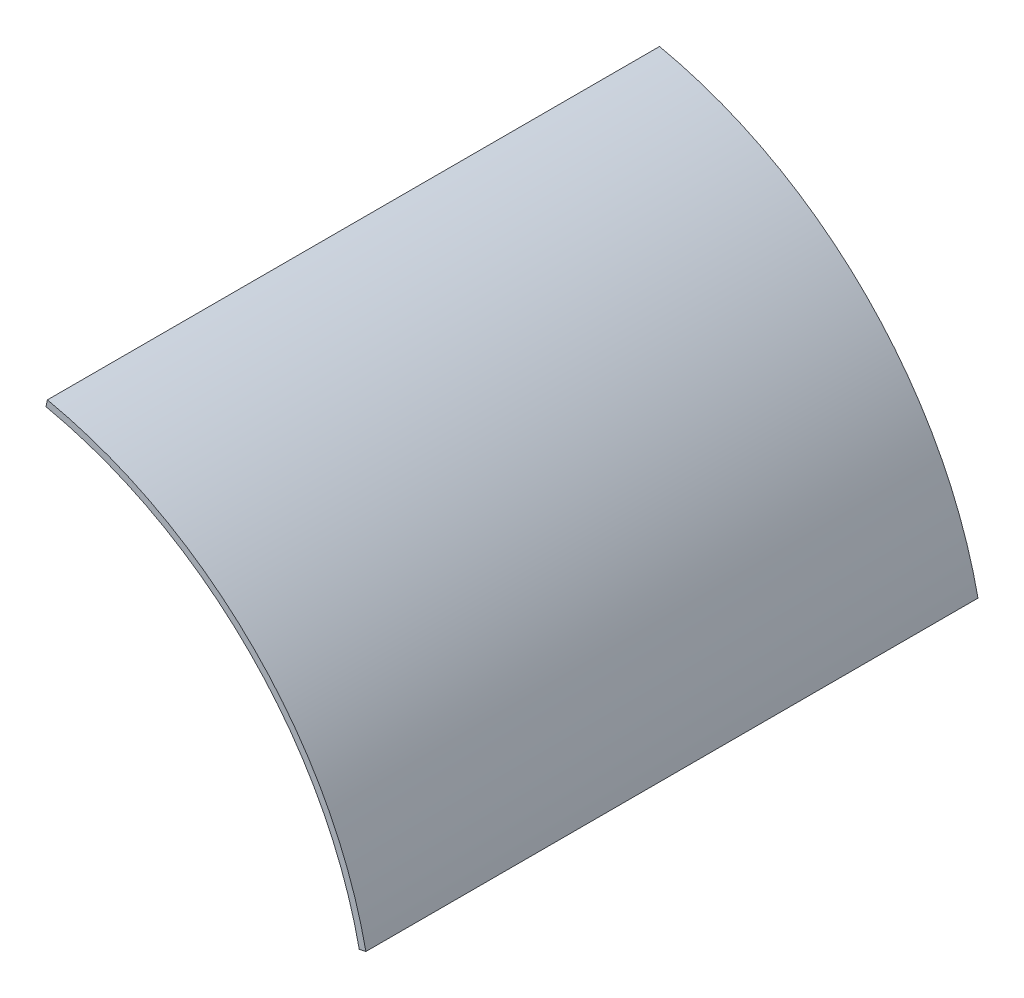
from build123d import *

# Parameters (mm, degrees)
SALIENTE_EXTRUIR1_DEPTH = 45


with BuildPart() as part:
    # Croquis1 → Saliente-Extruir1 (new body)
    with BuildSketch(Plane.XY):
        with BuildLine():
            Line((6.320515401, 29.735687062), (6.216559555, 29.246613262))
            ThreePointArc((6.216559555, 29.246613262), (21.142492757, 21.142492757), (29.246613262, 6.216559555))
            Line((29.246613262, 6.216559555), (29.735687062, 6.320515401))
            ThreePointArc((29.735687062, 6.320515401), (21.496046148, 21.496046148), (6.320515401, 29.735687062))
        make_face()
    extrude(amount=SALIENTE_EXTRUIR1_DEPTH)


solid = part.part
